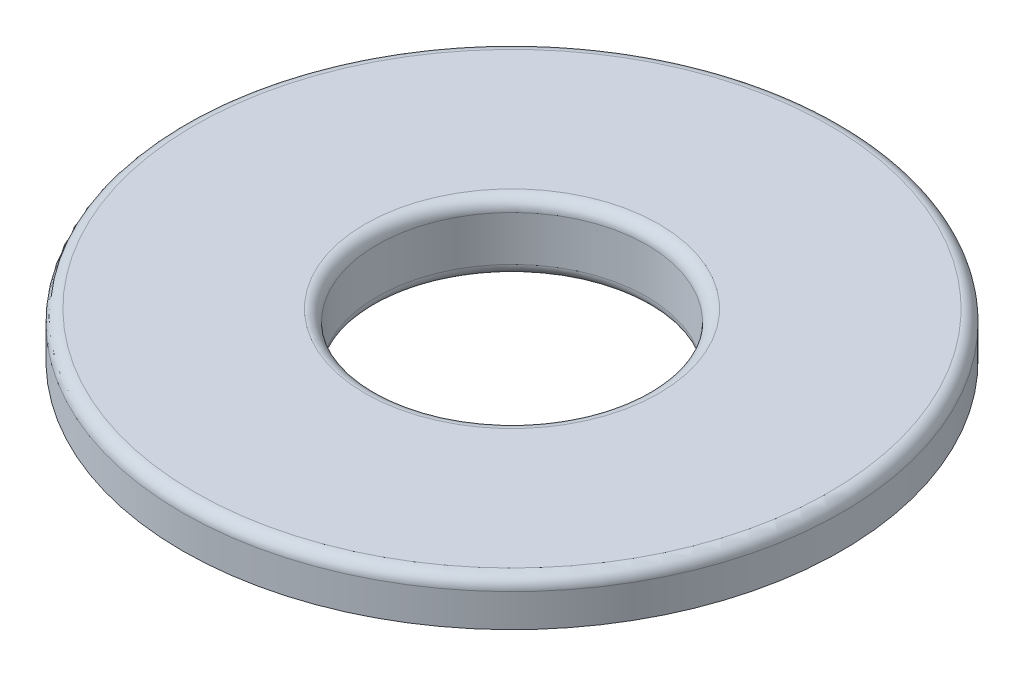
from build123d import *

# Parameters (mm, degrees)
SKETCH1_R           = 28.2575
BOSS_EXTRUDE1_DEPTH = 2.54
SKETCH2_R           = 34.925
BOSS_EXTRUDE2_DEPTH = 4.7625
CUT_EXTRUDE1_REACH  = 9.303
SKETCH3_R           = 14.2875
FILLET1_R           = 1.27


with BuildPart() as part:
    # Sketch1 → Boss-Extrude1 (new body)
    with BuildSketch(Plane(origin=(0, 0, 0), x_dir=(1, 0, 0), z_dir=(0, 1, 0))):
        Circle(SKETCH1_R)
    extrude(amount=BOSS_EXTRUDE1_DEPTH)

    # Sketch2 → Boss-Extrude2 (add)
    with BuildSketch(Plane(origin=(0, 2.54, 0), x_dir=(1, 0, 0), z_dir=(0, 1, 0))):
        Circle(SKETCH2_R)
    extrude(amount=BOSS_EXTRUDE2_DEPTH)

    # Sketch3 → Cut-Extrude1 (cut, up to next)
    with BuildSketch(Plane.XZ, mode=Mode.PRIVATE) as cut_extrude1_sk1:
        Circle(SKETCH3_R)
    cut_extrude1_tool1 = extrude(cut_extrude1_sk1.sketch, amount=-CUT_EXTRUDE1_REACH, mode=Mode.PRIVATE) & part.part
    add(cut_extrude1_tool1.solids().sort_by_distance((0, 0, 0))[0], mode=Mode.SUBTRACT)

    # Fillet1
    fillet1_edges = [part.edges().sort_by_distance(p)[0] for p in [
        (-14.2875, 7.3025, 0),
        (-14.2875, 0, 0),
        (-28.2575, 0, 0),
        (-34.925, 7.3025, 0),
    ]]
    fillet(fillet1_edges, radius=FILLET1_R)


solid = part.part
